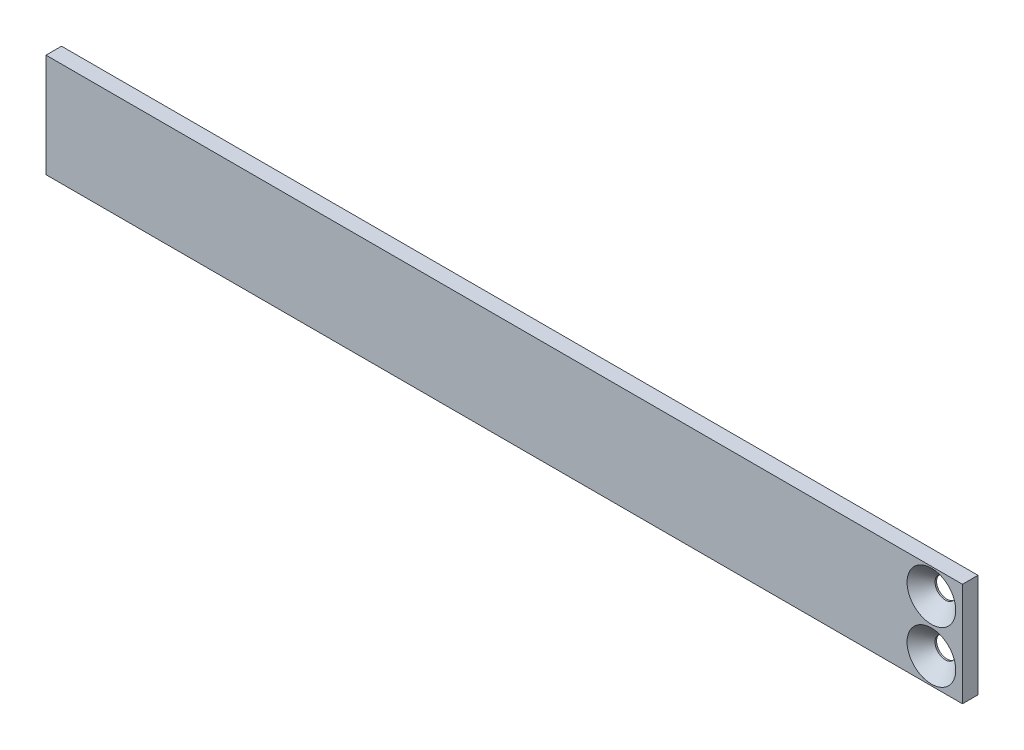
from build123d import *

# Parameters (mm, degrees)
SKIZZE1_W                       = 177
SKIZZE1_H                       = 20
AUFSATZ_LINEAR_AUSTRAGEN1_DEPTH = 3
SKIZZE3_R                       = 2
SCHNITT_LINEAR_AUSTRAGEN1_DEPTH = 8
FASE1_SIZE                      = 2.7
SKIZZE5_R                       = 2
SCHNITT_LINEAR_AUSTRAGEN2_DEPTH = 8
FASE2_SIZE                      = 2.7


with BuildPart() as part:
    # Skizze1 → Aufsatz-Linear austragen1 (new body)
    with BuildSketch(Plane.XY):
        with Locations((88.5, 10)):
            Rectangle(SKIZZE1_W, SKIZZE1_H)
    extrude(amount=AUFSATZ_LINEAR_AUSTRAGEN1_DEPTH)

    # Skizze3 → Schnitt-Linear austragen1 (cut)
    with BuildSketch(Plane.XY.offset(3)):
        with Locations((171, 5)):
            Circle(SKIZZE3_R)
    extrude(amount=-SCHNITT_LINEAR_AUSTRAGEN1_DEPTH, mode=Mode.SUBTRACT)

    # Fase1
    fase1_edges = [part.edges().sort_by_distance(p)[0] for p in [
        (169, 5, 3),
    ]]
    chamfer(fase1_edges, length=FASE1_SIZE)

    # Skizze5 → Schnitt-Linear austragen2 (cut)
    with BuildSketch(Plane.XY.offset(3)):
        with Locations((171, 15)):
            Circle(SKIZZE5_R)
    extrude(amount=-SCHNITT_LINEAR_AUSTRAGEN2_DEPTH, mode=Mode.SUBTRACT)

    # Fase2
    fase2_edges = [part.edges().sort_by_distance(p)[0] for p in [
        (169, 15, 3),
    ]]
    chamfer(fase2_edges, length=FASE2_SIZE)


solid = part.part
